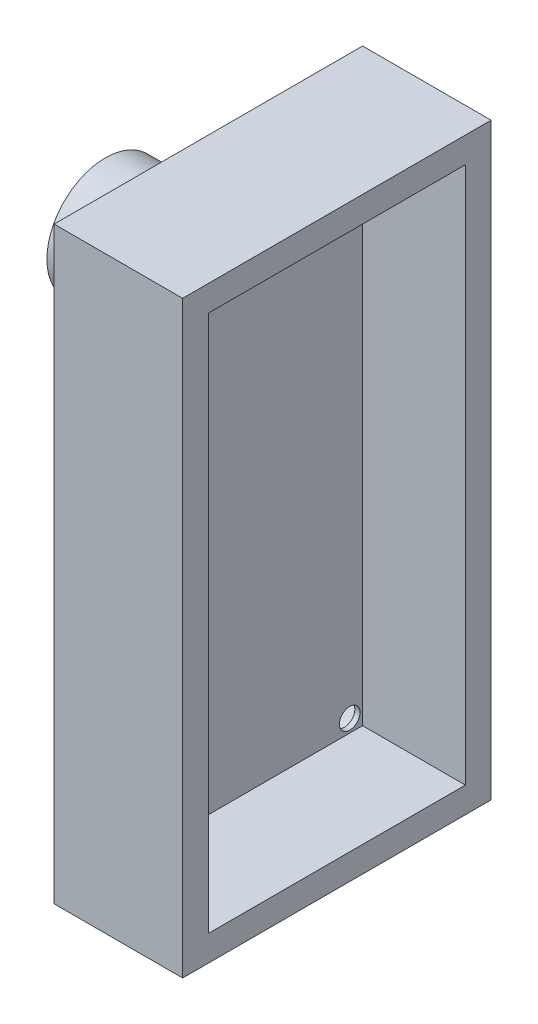
from build123d import *

# Parameters (mm, degrees)
CROQUIS1_W              = 12
CROQUIS1_H              = 22.9
SALIENTE_EXTRUIR1_DEPTH = 5
VACIADO2_T              = -1
CROQUIS2_R              = 2.28
SALIENTE_EXTRUIR2_DEPTH = 4
CROQUIS4_R              = 1
CORTAR_EXTRUIR1_DEPTH   = 0.8
CROQUIS5_R              = 0.4
CORTAR_EXTRUIR2_DEPTH   = 0.8


with BuildPart() as part:
    # Croquis1 → Saliente-Extruir1 (new body)
    with BuildSketch(Plane(origin=(0, 0, 0), x_dir=(0, 0, -1), z_dir=(1, 0, 0))):
        with Locations((-17.987585454, -24.1598532)):
            Rectangle(CROQUIS1_W, CROQUIS1_H)
    extrude(amount=SALIENTE_EXTRUIR1_DEPTH)

    # Vaciado2
    vaciado2_openings = [part.faces().sort_by_distance(p)[0] for p in [
        (5, -24.1598532, 17.987585454),
    ]]
    offset(amount=VACIADO2_T, openings=vaciado2_openings, kind=Kind.INTERSECTION)

    # Croquis2 → Saliente-Extruir2 (add)
    with BuildSketch(Plane.ZY):
        with Locations((17.987585454, -17.75436054)):
            Circle(CROQUIS2_R)
    extrude(amount=SALIENTE_EXTRUIR2_DEPTH)

    # Croquis4 → Cortar-Extruir1 (cut)
    with BuildSketch(Plane.ZY):
        with Locations((13.487585454, -14.2098532)):
            Circle(CROQUIS4_R)
        with Locations((22.487585454, -14.2098532)):
            Circle(CROQUIS4_R)
        with Locations((13.487585454, -34.1098532)):
            Circle(CROQUIS4_R)
        with Locations((22.487585454, -34.1098532)):
            Circle(CROQUIS4_R)
    extrude(amount=-CORTAR_EXTRUIR1_DEPTH, mode=Mode.SUBTRACT)

    # Croquis5 → Cortar-Extruir2 (cut)
    with BuildSketch(Plane.ZY.offset(-0.8)):
        with Locations((13.487585454, -14.2098532)):
            Circle(CROQUIS5_R)
        with Locations((22.487585454, -14.2098532)):
            Circle(CROQUIS5_R)
        with Locations((13.487585454, -34.1098532)):
            Circle(CROQUIS5_R)
        with Locations((22.487585454, -34.1098532)):
            Circle(CROQUIS5_R)
    extrude(amount=-CORTAR_EXTRUIR2_DEPTH, mode=Mode.SUBTRACT)


solid = part.part
